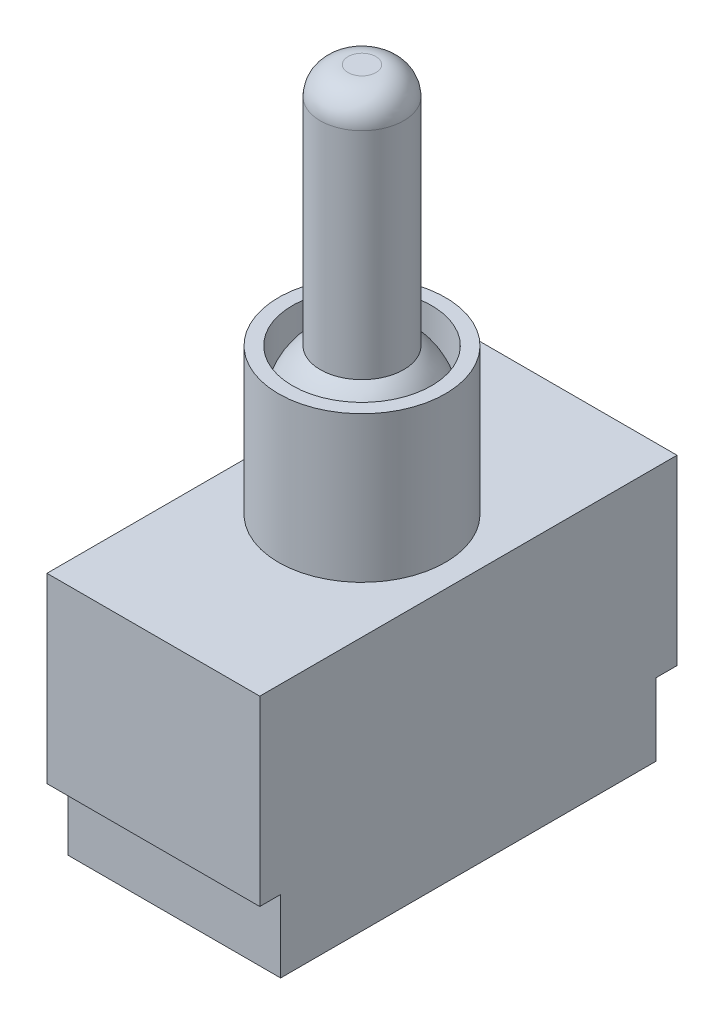
from build123d import *

# Parameters (mm, degrees)
SKETCH1_W           = 15.3
SKETCH1_H           = 30
BOSS_EXTRUDE1_DEPTH = 13.1
SKETCH2_R           = 6
BOSS_EXTRUDE2_DEPTH = 10.5
SKETCH4_R           = 5
CUT_EXTRUDE1_DEPTH  = 4
SKETCH5_R           = 3
BOSS_EXTRUDE3_DEPTH = 21.5
REVOLVE2_ANGLE      = 180
FILLET1_R           = 2
SKETCH6_W           = 15.3
SKETCH6_H           = 27
BOSS_EXTRUDE4_DEPTH = 5.2


with BuildPart() as part:
    # Sketch1 → Boss-Extrude1 (new body)
    with BuildSketch(Plane(origin=(0, 0, 0), x_dir=(1, 0, 0), z_dir=(0, 1, 0))):
        Rectangle(SKETCH1_W, SKETCH1_H)
    extrude(amount=BOSS_EXTRUDE1_DEPTH)

    # Sketch2 → Boss-Extrude2 (add)
    with BuildSketch(Plane(origin=(0, 13.1, 0), x_dir=(1, 0, 0), z_dir=(0, 1, 0))):
        Circle(SKETCH2_R)
    extrude(amount=BOSS_EXTRUDE2_DEPTH)

    # Sketch4 → Cut-Extrude1 (cut)
    with BuildSketch(Plane(origin=(0, 23.6, 0), x_dir=(1, 0, 0), z_dir=(0, 1, 0))):
        Circle(SKETCH4_R)
    extrude(amount=-CUT_EXTRUDE1_DEPTH, mode=Mode.SUBTRACT)

    # Sketch5 → Boss-Extrude3 (add)
    with BuildSketch(Plane(origin=(0, 19.6, 0), x_dir=(1, 0, 0), z_dir=(0, 1, 0))):
        Circle(SKETCH5_R)
    extrude(amount=BOSS_EXTRUDE3_DEPTH)

    # Sketch3 → Revolve2 (revolve)
    with BuildSketch(Plane(origin=(0, 19.6, 0), x_dir=(1, 0, 0), z_dir=(0, 1, 0))):
        with BuildLine():
            Line((0, -5), (0, 5))
            ThreePointArc((0, 5), (-5, 0), (0, -5))
        make_face()
    revolve(axis=Axis((0, 19.6, 6), (0, 0, -1)), revolution_arc=REVOLVE2_ANGLE)

    # Fillet1
    fillet1_edges = [part.edges().sort_by_distance(p)[0] for p in [
        (-3, 41.1, 0),
    ]]
    fillet(fillet1_edges, radius=FILLET1_R)

    # Sketch6 → Boss-Extrude4 (add)
    with BuildSketch(Plane.XZ):
        Rectangle(SKETCH6_W, SKETCH6_H)
    extrude(amount=BOSS_EXTRUDE4_DEPTH)


solid = part.part
